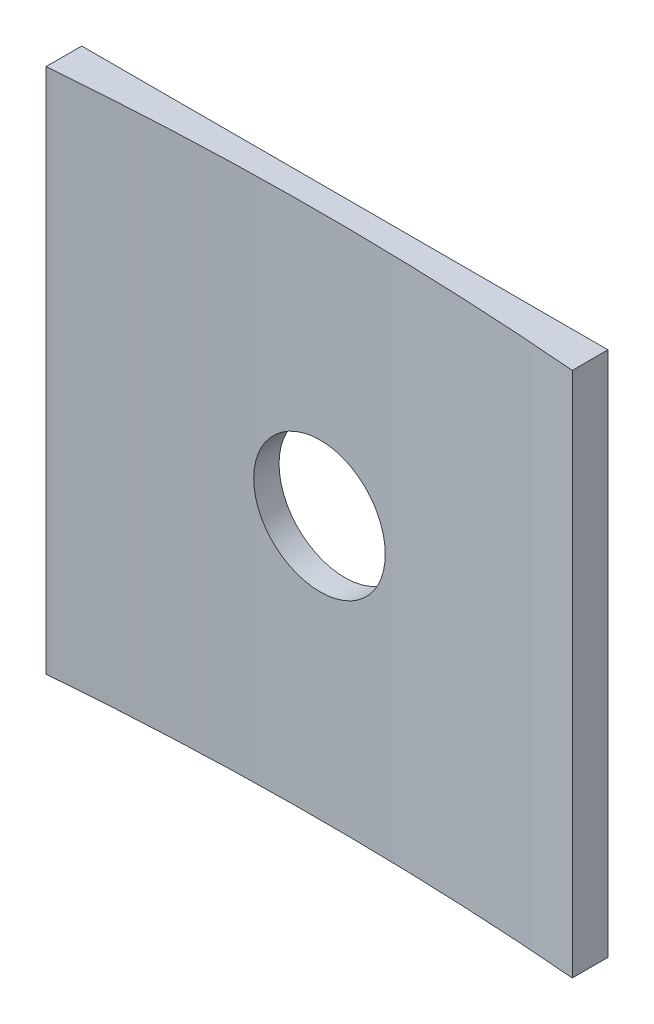
from build123d import *

# Parameters (mm, degrees)
BOSS_EXTRUDE1_DEPTH = 25.4
SKETCH2_R           = 3.175
CUT_EXTRUDE1_DEPTH  = 1.7209262


with BuildPart() as part:
    # Sketch1 → Boss-Extrude1 (new body)
    with BuildSketch(Plane(origin=(0, 0, 0), x_dir=(1, 0, 0), z_dir=(0, 1, 0))):
        with BuildLine():
            Line((-12.7, 151.869911437), (-12.7, 153.590837637))
            Line((-12.7, 153.590837637), (12.7, 153.590837637))
            Line((12.7, 153.590837637), (12.7, 151.869911437))
            ThreePointArc((12.7, 151.869911437), (6.355528969, 152.267420191), (0, 152.4))
            ThreePointArc((0, 152.4), (-6.355528969, 152.267420191), (-12.7, 151.869911437))
        make_face()
    extrude(amount=-BOSS_EXTRUDE1_DEPTH)

    # Sketch2 → Cut-Extrude1 (cut)
    with BuildSketch(Plane(origin=(0, 0, -153.590837637), x_dir=(-1, 0, 0), z_dir=(0, 0, -1))):
        with Locations((0, -12.7)):
            Circle(SKETCH2_R)
    extrude(amount=-CUT_EXTRUDE1_DEPTH, mode=Mode.SUBTRACT)


solid = part.part
